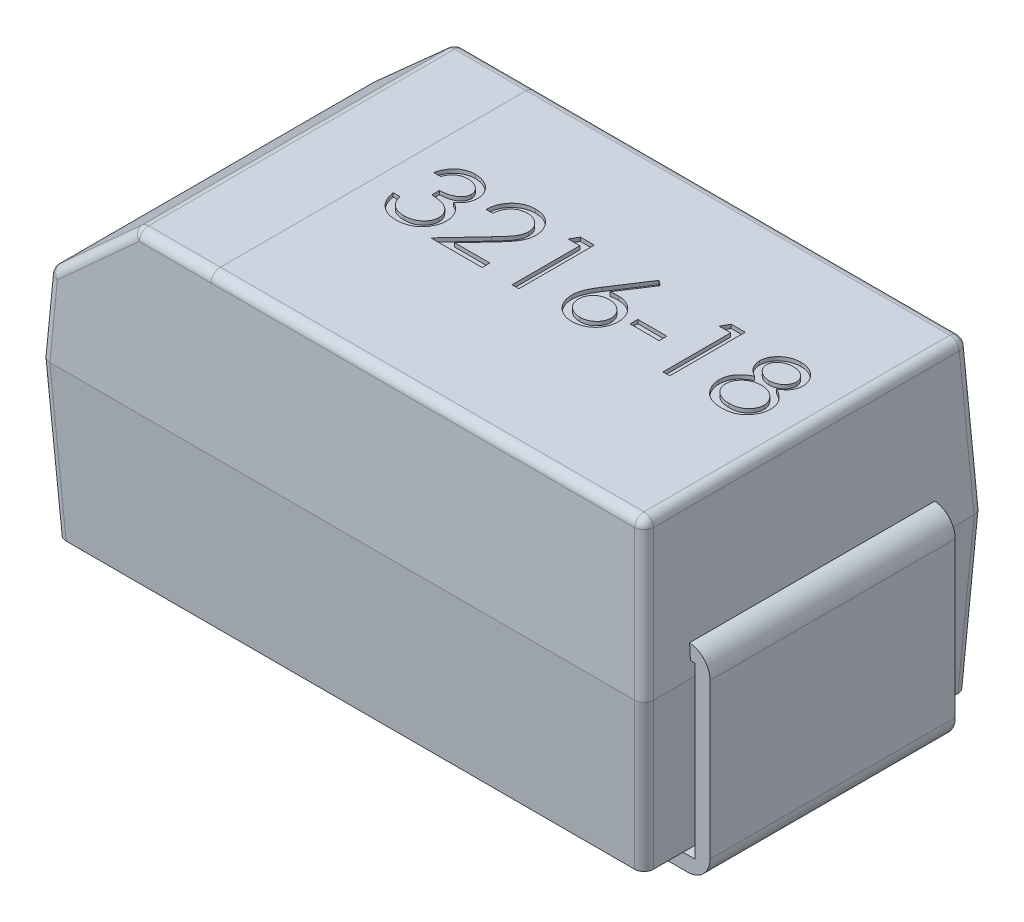
from build123d import *

# Parameters (mm, degrees)
SKETCH4_W                     = 3.2
SKETCH4_H                     = 1.8
BOSS_EXTRUDE2_DEPTH           = 0.82
BOSS_EXTRUDE2_TAPER           = 3
BOSS_EXTRUDE2_OTHER_WAY_DEPTH = 0.8
BOSS_EXTRUDE2_OTHER_WAY_TAPER = 3
SKETCH5_W                     = 1.1
SKETCH5_H                     = 1.3
BOSS_EXTRUDE3_DEPTH           = 0.06
BOSS_EXTRUDE7_DEPTH           = 0.65
BOSS_EXTRUDE7_2_DEPTH         = 0.65
CHAMFER1_SIZE                 = 0.4
CHAMFER1_SIZE2                = 0.422701801
SKETCH11_W                    = 0.153846154
SKETCH11_H                    = 0.041025641
CUT_EXTRUDE2_DEPTH            = 0.02
FILLET6_R                     = 0.05


with BuildPart() as part:
    # Sketch4 → Boss-Extrude2 (new body)
    with BuildSketch(Plane(origin=(0, 0.9, 0), x_dir=(-1, 0, 0), z_dir=(0, 1, 0))):
        Rectangle(SKETCH4_W, SKETCH4_H)
    extrude(amount=-BOSS_EXTRUDE2_DEPTH, taper=BOSS_EXTRUDE2_TAPER)

    # Sketch4 → Boss-Extrude2 other way (add)
    with BuildSketch(Plane(origin=(0, 0.9, 0), x_dir=(-1, 0, 0), z_dir=(0, 1, 0))):
        Rectangle(SKETCH4_W, SKETCH4_H)
    extrude(amount=BOSS_EXTRUDE2_OTHER_WAY_DEPTH, taper=BOSS_EXTRUDE2_OTHER_WAY_TAPER)

    # Sketch5 → Boss-Extrude3 (add)
    with BuildSketch(Plane.XZ.offset(-0.08)):
        Rectangle(SKETCH5_W, SKETCH5_H)
    extrude(amount=BOSS_EXTRUDE3_DEPTH)

    # Chamfer1
    chamfer1_edges = [part.edges().sort_by_distance(p)[0] for p in [
        (-1.558073777, 1.7, 0),
    ]]
    chamfer1_side = [part.faces().sort_by_distance(p)[0] for p in [
        (-1.57920353, 1.296820291, 0),
    ]]
    chamfer(chamfer1_edges, length=CHAMFER1_SIZE, length2=CHAMFER1_SIZE2, reference=chamfer1_side[0])

    # Sketch11 → Cut-Extrude2 (cut)
    with BuildSketch(Plane(origin=(0, 1.7, 0), x_dir=(1, 0, 0), z_dir=(0, 1, 0))):
        with BuildLine():
            Line((-0.568705309, 0.189618531), (-0.604602745, 0.189618531))
            add(Edge.make_bspline(
                [(-0.604602745, 0.189618531), (-0.603630225, 0.193645101), (-0.601729027, 0.201516715), (-0.59776359, 0.212763259), (-0.593443676, 0.223405947), (-0.588256349, 0.233245498), (-0.582598206, 0.242479659), (-0.576115609, 0.250898987), (-0.569107641, 0.258717612), (-0.561356218, 0.265656268), (-0.553227228, 0.271939437), (-0.544606129, 0.277296586), (-0.53566637, 0.281905061), (-0.526346012, 0.285701659), (-0.516617306, 0.288561718), (-0.506568206, 0.290636782), (-0.496172378, 0.291984338), (-0.48911551, 0.292115854), (-0.485532232, 0.292182634)],
                knots=[0, 0, 0, 0, 1.162005537, 2.271625781, 3.343758855, 4.383309926, 5.390229558, 6.379919256, 7.361854164, 8.333198761, 9.295911338, 10.242430842, 11.177959212, 12.116337295, 13.062827104, 14.020064771, 14.994644689, 16, 16, 16, 16], degree=3))
            add(Edge.make_bspline(
                [(-0.485532232, 0.292182634), (-0.480311347, 0.292025007), (-0.46998346, 0.291713193), (-0.45481054, 0.288865829), (-0.440178904, 0.284360099), (-0.426248704, 0.278134531), (-0.413309455, 0.270455981), (-0.401796748, 0.261317153), (-0.391866632, 0.250894376), (-0.383535846, 0.239382083), (-0.377012989, 0.227078596), (-0.372203118, 0.214415721), (-0.369274926, 0.201423496), (-0.368895434, 0.192651235), (-0.368705309, 0.188256352)],
                knots=[0, 0, 0, 0, 1.083050992, 2.142477498, 3.193116406, 4.255571735, 5.30263384, 6.308962982, 7.297363603, 8.282367274, 9.249857812, 10.179914175, 11.08814088, 12, 12, 12, 12], degree=3))
            add(Edge.make_bspline(
                [(-0.368705309, 0.188256352), (-0.368838291, 0.184027004), (-0.369098515, 0.175750826), (-0.371308082, 0.163668369), (-0.375026512, 0.152280758), (-0.380177342, 0.141540053), (-0.386844948, 0.131514358), (-0.394921827, 0.122181113), (-0.404464989, 0.113498923), (-0.411696867, 0.108525269), (-0.415420052, 0.105964685)],
                knots=[0, 0, 0, 0, 1.024540389, 2.004866551, 2.965041327, 3.920577974, 4.882998113, 5.874504559, 6.905732034, 8, 8, 8, 8], degree=3))
            add(Edge.make_bspline(
                [(-0.415420052, 0.105964685), (-0.411164995, 0.103910037), (-0.402734495, 0.099839184), (-0.391243006, 0.091855669), (-0.380811249, 0.082637801), (-0.374993681, 0.075444355), (-0.372070693, 0.07183007)],
                knots=[0, 0, 0, 0, 1.015518401, 2.012035669, 3.001164323, 4, 4, 4, 4], degree=3))
            add(Edge.make_bspline(
                [(-0.372070693, 0.07183007), (-0.370145969, 0.069194898), (-0.366328038, 0.063967708), (-0.361615405, 0.055563545), (-0.357340078, 0.047066231), (-0.354008624, 0.038248014), (-0.351428754, 0.029211098), (-0.349584636, 0.019939967), (-0.34843902, 0.01042705), (-0.348274957, 0.003991338), (-0.348192488, 0.000756352)],
                knots=[0, 0, 0, 0, 1.025084078, 2.033381695, 3.024893161, 4.013698104, 4.991890475, 5.976764909, 6.982997093, 8, 8, 8, 8], degree=3))
            add(Edge.make_bspline(
                [(-0.348192488, 0.000756352), (-0.348397576, -0.004844759), (-0.348806785, -0.016020622), (-0.352464393, -0.032532019), (-0.358134478, -0.048672077), (-0.366186699, -0.064109201), (-0.376000129, -0.078552673), (-0.387675252, -0.09147568), (-0.401079413, -0.102584092), (-0.41602863, -0.111865261), (-0.432224873, -0.119284452), (-0.449547798, -0.124433874), (-0.467747804, -0.127787702), (-0.480228638, -0.128147345), (-0.486573899, -0.128330187)],
                knots=[0, 0, 0, 0, 0.955779014, 1.907060117, 2.875433937, 3.871313158, 4.872415639, 5.851225146, 6.836215519, 7.83643374, 8.849228613, 9.86973379, 10.916971861, 12, 12, 12, 12], degree=3))
            add(Edge.make_bspline(
                [(-0.486573899, -0.128330187), (-0.49085039, -0.128230962), (-0.499265099, -0.128035722), (-0.511635785, -0.126701025), (-0.523443979, -0.12426331), (-0.534705647, -0.120982932), (-0.545430794, -0.116823876), (-0.555586692, -0.111644596), (-0.565235823, -0.105551853), (-0.574287131, -0.098473729), (-0.582739539, -0.090555861), (-0.590368422, -0.081657689), (-0.59730097, -0.0719437), (-0.603351557, -0.061301065), (-0.60879578, -0.049867321), (-0.613273604, -0.037496064), (-0.617214812, -0.02429789), (-0.619047207, -0.015100434), (-0.61998736, -0.010381469)],
                knots=[0, 0, 0, 0, 1.048658725, 2.063410685, 3.046034179, 4.001477787, 4.936774919, 5.862367409, 6.792675028, 7.730719943, 8.675894397, 9.627829632, 10.600096036, 11.597688215, 12.626045268, 13.701542398, 14.82072376, 16, 16, 16, 16], degree=3))
            Line((-0.61998736, -0.010381469), (-0.584089924, -0.010381469))
            add(Edge.make_bspline(
                [(-0.584089924, -0.010381469), (-0.583154691, -0.013461356), (-0.581335581, -0.019452004), (-0.57823909, -0.028073754), (-0.574711287, -0.035977531), (-0.570926766, -0.043221316), (-0.566952087, -0.049876448), (-0.562504667, -0.055766947), (-0.557913907, -0.061151542), (-0.55445341, -0.064185212), (-0.552759796, -0.06566993)],
                knots=[0, 0, 0, 0, 1.198163088, 2.33053128, 3.407730985, 4.417276592, 5.372219308, 6.28897303, 7.162600585, 8, 8, 8, 8], degree=3))
            add(Edge.make_bspline(
                [(-0.552759796, -0.06566993), (-0.550520187, -0.067396597), (-0.546047883, -0.070844601), (-0.538760085, -0.075244787), (-0.531095527, -0.079057476), (-0.522888135, -0.081969898), (-0.514315019, -0.084435916), (-0.505237606, -0.08604969), (-0.495735981, -0.087156909), (-0.489248236, -0.087254616), (-0.485932873, -0.087304546)],
                knots=[0, 0, 0, 0, 0.946170439, 1.889420265, 2.845303464, 3.807233317, 4.801018734, 5.828864929, 6.890507805, 8, 8, 8, 8], degree=3))
            add(Edge.make_bspline(
                [(-0.485932873, -0.087304546), (-0.482189615, -0.087234157), (-0.474869999, -0.087096517), (-0.464189443, -0.085830722), (-0.454028592, -0.083987246), (-0.444500258, -0.081140048), (-0.435479628, -0.077622236), (-0.427093154, -0.073205276), (-0.419230742, -0.068023022), (-0.411993096, -0.062132832), (-0.405485038, -0.055684661), (-0.399754808, -0.04894031), (-0.394883418, -0.041928215), (-0.390953866, -0.034609573), (-0.387850946, -0.02701469), (-0.38573858, -0.019122252), (-0.384269836, -0.01099685), (-0.384150223, -0.00547354), (-0.384089924, -0.002689161)],
                knots=[0, 0, 0, 0, 1.217147791, 2.380027433, 3.494444702, 4.572153297, 5.609568379, 6.639424714, 7.649109417, 8.668170816, 9.669597737, 10.625200337, 11.543417969, 12.441394052, 13.322311151, 14.205496177, 15.095365482, 16, 16, 16, 16], degree=3))
            add(Edge.make_bspline(
                [(-0.384089924, -0.002689161), (-0.384264816, 0.001037849), (-0.384613729, 0.008473324), (-0.387277566, 0.019412476), (-0.391659151, 0.029952294), (-0.397793152, 0.039912956), (-0.405260093, 0.049144487), (-0.413987511, 0.057381228), (-0.424047879, 0.06417781), (-0.433307293, 0.068873657), (-0.441509025, 0.072077894), (-0.448527926, 0.074212175), (-0.456385824, 0.07601945), (-0.464987692, 0.077700853), (-0.474398346, 0.079131864), (-0.484607539, 0.080325214), (-0.49561734, 0.081280076), (-0.503239187, 0.081706487), (-0.507166847, 0.081926223)],
                knots=[0, 0, 0, 0, 1.07054697, 2.135767047, 3.216561865, 4.33974944, 5.486079747, 6.621378074, 7.775625952, 8.963672916, 9.598146892, 10.304877434, 11.070270905, 11.915000392, 12.823868403, 13.805723172, 14.86925407, 16, 16, 16, 16], degree=3))
            Line((-0.507166847, 0.081926223), (-0.507166847, 0.122951864))
            add(Edge.make_bspline(
                [(-0.507166847, 0.122951864), (-0.502218143, 0.123035842), (-0.492524846, 0.123200333), (-0.478365497, 0.12518982), (-0.46482569, 0.127941892), (-0.452205491, 0.132157343), (-0.44070278, 0.137053377), (-0.430723397, 0.142750772), (-0.422407152, 0.149083886), (-0.415794458, 0.15615047), (-0.410819689, 0.163729333), (-0.407182341, 0.171628379), (-0.405033732, 0.179916843), (-0.404746913, 0.185573377), (-0.404602745, 0.188416608)],
                knots=[0, 0, 0, 0, 1.321986639, 2.589447074, 3.816329219, 5.01088745, 6.139805852, 7.153945165, 8.075214402, 8.924034688, 9.728124013, 10.488707548, 11.240355623, 12, 12, 12, 12], degree=3))
            add(Edge.make_bspline(
                [(-0.404602745, 0.188416608), (-0.404650106, 0.190505493), (-0.404744329, 0.194661231), (-0.405932589, 0.200732668), (-0.407718194, 0.20661849), (-0.41017302, 0.212293668), (-0.413458757, 0.217718842), (-0.41739087, 0.222940265), (-0.422072938, 0.227928126), (-0.427438132, 0.232577305), (-0.433199482, 0.237008075), (-0.439513742, 0.240769633), (-0.446190527, 0.243986212), (-0.453237231, 0.246638727), (-0.46067672, 0.248634074), (-0.468474041, 0.250066741), (-0.476644062, 0.250962473), (-0.482217974, 0.251091435), (-0.485051463, 0.251156993)],
                knots=[0, 0, 0, 0, 0.884392785, 1.759457502, 2.611959086, 3.489218968, 4.37281399, 5.2945488, 6.255912374, 7.266815255, 8.301784654, 9.332968512, 10.37626691, 11.440494194, 12.520033166, 13.637162961, 14.798855837, 16, 16, 16, 16], degree=3))
            add(Edge.make_bspline(
                [(-0.485051463, 0.251156993), (-0.489605939, 0.25099798), (-0.498501891, 0.250687391), (-0.511326453, 0.247967046), (-0.523248662, 0.243626694), (-0.532361653, 0.238445778), (-0.53909109, 0.233331442), (-0.543899883, 0.228864884), (-0.548622227, 0.223901133), (-0.552947447, 0.218134461), (-0.557321616, 0.211955399), (-0.561303851, 0.205049836), (-0.56517353, 0.197597905), (-0.56750525, 0.192329832), (-0.568705309, 0.189618531)],
                knots=[0, 0, 0, 0, 1.472543308, 2.876219568, 4.221790263, 5.565193594, 6.249813518, 6.953379497, 7.687249741, 8.463570142, 9.283606569, 10.136032583, 11.040678096, 12, 12, 12, 12], degree=3))
        make_face()
        with BuildLine():
            Line((-0.261013001, 0.1588493), (-0.296910437, 0.1588493))
            add(Edge.make_bspline(
                [(-0.296910437, 0.1588493), (-0.296676477, 0.163611688), (-0.296216985, 0.172964889), (-0.29406518, 0.186601907), (-0.290986223, 0.199636741), (-0.286632914, 0.211964731), (-0.281226482, 0.223694881), (-0.27474305, 0.234780597), (-0.267063753, 0.24517959), (-0.258354412, 0.254795458), (-0.248895139, 0.263616894), (-0.238688746, 0.271234636), (-0.2279636, 0.277670942), (-0.21675224, 0.283051655), (-0.204928176, 0.287090495), (-0.192598706, 0.290087253), (-0.179709662, 0.291890264), (-0.170927945, 0.292084068), (-0.166461719, 0.292182634)],
                knots=[0, 0, 0, 0, 1.10065271, 2.161652631, 3.183658789, 4.190468796, 5.17591951, 6.163126047, 7.15150782, 8.156236427, 9.156009102, 10.134482811, 11.092018607, 12.041330605, 13.001268258, 13.972401359, 14.968799086, 16, 16, 16, 16], degree=3))
            add(Edge.make_bspline(
                [(-0.166461719, 0.292182634), (-0.162075653, 0.292079953), (-0.153457191, 0.291878189), (-0.140878675, 0.2901455), (-0.128904127, 0.287431718), (-0.117556954, 0.283624242), (-0.106927689, 0.278506022), (-0.096936484, 0.272357731), (-0.087464392, 0.265246894), (-0.078937902, 0.256875029), (-0.071108407, 0.247937614), (-0.064353864, 0.238396139), (-0.058569502, 0.228541364), (-0.053748053, 0.218298141), (-0.05019878, 0.207570023), (-0.047504128, 0.1965132), (-0.045980995, 0.185013221), (-0.045747232, 0.177229615), (-0.045628386, 0.173272377)],
                knots=[0, 0, 0, 0, 1.111607364, 2.184268762, 3.212621178, 4.221274766, 5.211760367, 6.196651075, 7.1921475, 8.207485113, 9.220403448, 10.201281604, 11.166441695, 12.114753415, 13.065576456, 14.026450734, 14.996634279, 16, 16, 16, 16], degree=3))
            add(Edge.make_bspline(
                [(-0.045628386, 0.173272377), (-0.045821901, 0.167701196), (-0.046205537, 0.1566566), (-0.04948718, 0.14042633), (-0.054612496, 0.124701368), (-0.060783622, 0.112045676), (-0.067009044, 0.101847563), (-0.072619045, 0.093451139), (-0.079186452, 0.084410515), (-0.086806852, 0.074755962), (-0.095322609, 0.064411858), (-0.104810856, 0.053384453), (-0.115339254, 0.041787679), (-0.122728797, 0.033867039), (-0.126557873, 0.029762762)],
                knots=[0, 0, 0, 0, 1.184426356, 2.348067706, 3.509069118, 4.696110526, 5.333549288, 6.050745305, 6.844228056, 7.710549037, 8.667450064, 9.695053472, 10.805634456, 12, 12, 12, 12], degree=3))
            Line((-0.126557873, 0.029762762), (-0.226638001, -0.077048136))
            Line((-0.226638001, -0.077048136), (-0.040500181, -0.077048136))
            Line((-0.040500181, -0.077048136), (-0.040500181, -0.118073777))
            Line((-0.040500181, -0.118073777), (-0.312295052, -0.118073777))
            Line((-0.312295052, -0.118073777), (-0.157166847, 0.047471095))
            add(Edge.make_bspline(
                [(-0.157166847, 0.047471095), (-0.153389946, 0.051413759), (-0.146135291, 0.058986809), (-0.135874425, 0.070043147), (-0.126658541, 0.080300237), (-0.118427982, 0.0897387), (-0.111361296, 0.098496594), (-0.105090183, 0.106290274), (-0.100065544, 0.113462211), (-0.094612356, 0.121775424), (-0.089330758, 0.131925403), (-0.084792203, 0.144329253), (-0.082024792, 0.157098082), (-0.081692811, 0.165726887), (-0.081525822, 0.170067249)],
                knots=[0, 0, 0, 0, 1.329631726, 2.553950428, 3.673215718, 4.687767853, 5.603093632, 6.413772471, 7.123043292, 7.734684054, 8.834405432, 9.900288307, 10.943827018, 12, 12, 12, 12], degree=3))
            add(Edge.make_bspline(
                [(-0.081525822, 0.170067249), (-0.081598478, 0.172796552), (-0.081741669, 0.178175483), (-0.083005406, 0.186061856), (-0.084915178, 0.193669263), (-0.087651779, 0.201021105), (-0.091263978, 0.208043465), (-0.095660936, 0.214744892), (-0.100734086, 0.221223631), (-0.106602803, 0.227298293), (-0.113049833, 0.23286186), (-0.119860605, 0.237790326), (-0.127066331, 0.241909082), (-0.134636631, 0.245285482), (-0.142550399, 0.247934097), (-0.150822941, 0.249769363), (-0.1594314, 0.250921647), (-0.165309514, 0.251077552), (-0.168304668, 0.251156993)],
                knots=[0, 0, 0, 0, 0.991446411, 1.95395049, 2.89581595, 3.838931463, 4.798493298, 5.75982156, 6.748411868, 7.785213223, 8.824556874, 9.840280684, 10.836137867, 11.835679398, 12.848801643, 13.863922112, 14.911575587, 16, 16, 16, 16], degree=3))
            add(Edge.make_bspline(
                [(-0.168304668, 0.251156993), (-0.171432763, 0.251075275), (-0.177575825, 0.250914794), (-0.186595143, 0.249792204), (-0.195199232, 0.247855536), (-0.203409735, 0.245206774), (-0.211240545, 0.241840082), (-0.218653579, 0.23764674), (-0.225632195, 0.232642912), (-0.232189512, 0.226969706), (-0.238231109, 0.220653409), (-0.243539324, 0.21361227), (-0.248177497, 0.205974851), (-0.252224266, 0.19776176), (-0.255510631, 0.18889847), (-0.258021848, 0.179416447), (-0.260008916, 0.169356861), (-0.260672747, 0.162409994), (-0.261013001, 0.1588493)],
                knots=[0, 0, 0, 0, 1.031018746, 2.02475058, 2.990194455, 3.934040569, 4.864654155, 5.795059489, 6.735614925, 7.690564532, 8.649604399, 9.611025574, 10.590972636, 11.591080095, 12.624614302, 13.701020113, 14.821632451, 16, 16, 16, 16], degree=3))
        make_face()
        Polygon((0.080413281, 0.281926223), (0.154371614, 0.281926223), (0.154371614, -0.118073777), (0.118474178, -0.118073777), (0.118474178, 0.240900582), (0.056935717, 0.240900582), align=None)
        with BuildLine():
            Line((0.487704948, 0.292182634), (0.515349178, 0.27046789))
            Line((0.515349178, 0.27046789), (0.409660076, 0.1088493))
            add(Edge.make_bspline(
                [(0.409660076, 0.1088493), (0.416696679, 0.109970884), (0.430422369, 0.112158661), (0.444315614, 0.112519569), (0.451086358, 0.112695454)],
                knots=[0, 0, 0, 0, 1.025318673, 2, 2, 2, 2], degree=3))
            add(Edge.make_bspline(
                [(0.451086358, 0.112695454), (0.455151786, 0.112586184), (0.46315446, 0.11237109), (0.474903809, 0.110715793), (0.486193973, 0.108107208), (0.496978158, 0.104304665), (0.50729507, 0.099447253), (0.517203915, 0.093625668), (0.52651843, 0.086539304), (0.535358565, 0.078623309), (0.543384519, 0.069855654), (0.550490354, 0.060552644), (0.55645913, 0.050723972), (0.561301864, 0.040374616), (0.565062422, 0.029520529), (0.567803867, 0.018175599), (0.569424392, 0.006332002), (0.569644448, -0.001722647), (0.56975623, -0.005814161)],
                knots=[0, 0, 0, 0, 1.04369286, 2.054478336, 3.041073146, 4.015093852, 4.984733326, 5.965804835, 6.960378782, 7.985147595, 9.009457201, 10.008161701, 10.986880575, 11.956520048, 12.937015923, 13.931873656, 14.949455224, 16, 16, 16, 16], degree=3))
            add(Edge.make_bspline(
                [(0.56975623, -0.005814161), (0.569593589, -0.011411842), (0.569273551, -0.022426752), (0.566084546, -0.038469804), (0.561129158, -0.05375352), (0.554046012, -0.068033883), (0.545248025, -0.081291319), (0.534519157, -0.09303823), (0.522239901, -0.103514805), (0.508355696, -0.112275562), (0.493413643, -0.119430196), (0.477716272, -0.124569081), (0.461416026, -0.127732906), (0.450352643, -0.128129546), (0.44475623, -0.128330187)],
                knots=[0, 0, 0, 0, 1.031375318, 2.029502543, 3.004789286, 3.987476834, 4.960371455, 5.9300674, 6.912260825, 7.929083631, 8.949397511, 9.960523116, 10.96833055, 12, 12, 12, 12], degree=3))
            add(Edge.make_bspline(
                [(0.44475623, -0.128330187), (0.43937375, -0.128155535), (0.428711999, -0.12780958), (0.413028251, -0.124727758), (0.397958192, -0.119732661), (0.383607406, -0.112851029), (0.370313621, -0.104158699), (0.358420406, -0.093694439), (0.34798706, -0.081681929), (0.339304246, -0.068123032), (0.332417534, -0.053552751), (0.327252971, -0.038359933), (0.324236258, -0.022599935), (0.323814708, -0.011916376), (0.323602383, -0.006535315)],
                knots=[0, 0, 0, 0, 1.012016664, 2.004627821, 2.994792927, 3.992885782, 4.990978636, 5.973936114, 6.964471063, 7.975201453, 8.993600317, 9.990122807, 10.98767138, 12, 12, 12, 12], degree=3))
            add(Edge.make_bspline(
                [(0.323602383, -0.006535315), (0.323737406, -0.002415934), (0.324013095, 0.005995055), (0.325938054, 0.018733801), (0.329031174, 0.03176821), (0.332495202, 0.042825832), (0.336155272, 0.051884292), (0.339201276, 0.059187548), (0.34299259, 0.066703099), (0.347035262, 0.074688658), (0.35169319, 0.082938421), (0.356757836, 0.091590269), (0.362369224, 0.100506604), (0.366302957, 0.106557369), (0.368313922, 0.109650582)],
                knots=[0, 0, 0, 0, 1.173818275, 2.396712641, 3.66331629, 4.989737886, 5.693666774, 6.447286557, 7.243889047, 8.091586357, 8.998013824, 9.943181721, 10.948533338, 12, 12, 12, 12], degree=3))
            Line((0.368313922, 0.109650582), (0.487704948, 0.292182634))
        make_face()
        with BuildLine():
            add(Edge.make_bspline(
                [(0.443554307, 0.071669813), (0.440507193, 0.071580894), (0.434555295, 0.071407209), (0.425823019, 0.070398608), (0.417558647, 0.068499287), (0.409652689, 0.066080277), (0.402252951, 0.062754213), (0.395305656, 0.058714008), (0.388783935, 0.053957302), (0.382756101, 0.048551483), (0.377290996, 0.042632851), (0.372584581, 0.036293477), (0.368524879, 0.029686139), (0.365224099, 0.022755632), (0.362653805, 0.015504603), (0.360794576, 0.007966403), (0.359759862, 9.0483e-05), (0.359587721, -0.005250375), (0.359499819, -0.007977623)],
                knots=[0, 0, 0, 0, 1.129588631, 2.206414736, 3.251139165, 4.268635594, 5.265702196, 6.250456724, 7.242448911, 8.251968645, 9.246821453, 10.222880186, 11.173611482, 12.116736599, 13.062300278, 14.020270554, 14.989073742, 16, 16, 16, 16], degree=3))
            add(Edge.make_bspline(
                [(0.359499819, -0.007977623), (0.359571404, -0.010680478), (0.359711769, -0.015980374), (0.36098632, -0.023790565), (0.362933187, -0.031306555), (0.365829232, -0.038489595), (0.369283734, -0.045449174), (0.373844342, -0.051933207), (0.378897689, -0.0583355), (0.384938139, -0.06416424), (0.391420809, -0.069587854), (0.39834666, -0.074328455), (0.405564941, -0.078384017), (0.413173104, -0.081562428), (0.421063205, -0.084170918), (0.429300983, -0.086006516), (0.437892166, -0.08704429), (0.443711816, -0.087216655), (0.446679307, -0.087304546)],
                knots=[0, 0, 0, 0, 0.989467248, 1.94019797, 2.891935182, 3.827694429, 4.772920941, 5.730924762, 6.725747692, 7.756678648, 8.79901574, 9.819492441, 10.826891316, 11.826466727, 12.835195252, 13.867842842, 14.912794438, 16, 16, 16, 16], degree=3))
            add(Edge.make_bspline(
                [(0.446679307, -0.087304546), (0.449646792, -0.087216649), (0.455466433, -0.08704427), (0.464057685, -0.086006594), (0.472295207, -0.084170634), (0.480186237, -0.08156346), (0.487790972, -0.07838019), (0.49500294, -0.074353685), (0.501863294, -0.0695587), (0.508350219, -0.064173509), (0.514365527, -0.058302326), (0.519540073, -0.051990357), (0.523961014, -0.045396769), (0.527553492, -0.03851701), (0.53041764, -0.031302212), (0.532374379, -0.023791729), (0.533646298, -0.015980069), (0.533787025, -0.010680375), (0.533858794, -0.007977623)],
                knots=[0, 0, 0, 0, 1.087397944, 2.132534446, 3.165364764, 4.174271784, 5.174024072, 6.181601208, 7.194203697, 8.236725232, 9.267838612, 10.269026844, 11.221737037, 12.171628256, 13.107553087, 14.05945871, 15.010357665, 16, 16, 16, 16], degree=3))
            add(Edge.make_bspline(
                [(0.533858794, -0.007977623), (0.533795903, -0.005246817), (0.533672469, 0.000112867), (0.532276361, 0.00796288), (0.53034009, 0.015542904), (0.527416315, 0.022805298), (0.523617852, 0.029721404), (0.518991177, 0.036326158), (0.513638884, 0.042670198), (0.507456308, 0.048563091), (0.500725995, 0.053951328), (0.493569928, 0.058707849), (0.486083303, 0.062722132), (0.478273709, 0.066071515), (0.470051666, 0.068488598), (0.461549912, 0.070391825), (0.452659713, 0.071404627), (0.446628101, 0.071580292), (0.443554307, 0.071669813)],
                knots=[0, 0, 0, 0, 0.978206639, 1.919901502, 2.851605144, 3.780102724, 4.718870031, 5.675451981, 6.667674623, 7.690630536, 8.733308323, 9.756129687, 10.767539656, 11.776269907, 12.797430371, 13.836405707, 14.897401972, 16, 16, 16, 16], degree=3))
        make_face(mode=Mode.SUBTRACT)
        with Locations((0.687704948, 0.035772378)):
            Rectangle(SKETCH11_W, SKETCH11_H)
        Polygon((0.880413281, 0.281926223), (0.954371614, 0.281926223), (0.954371614, -0.118073777), (0.918474178, -0.118073777), (0.918474178, 0.240900582), (0.856935717, 0.240900582), align=None)
        with BuildLine():
            add(Edge.make_bspline(
                [(1.297560717, 0.104762762), (1.300834837, 0.103055567), (1.307220463, 0.099725967), (1.316315001, 0.094364729), (1.32462643, 0.088714333), (1.332385351, 0.083041664), (1.339455449, 0.077129475), (1.345757667, 0.070954257), (1.351447681, 0.064670149), (1.356410742, 0.058170739), (1.360776095, 0.051473293), (1.36454891, 0.044560233), (1.367773733, 0.037446709), (1.370329498, 0.030055072), (1.372434845, 0.022493899), (1.373883486, 0.014665558), (1.374662562, 0.006621633), (1.374809855, 0.001185256), (1.374884435, -0.001567366)],
                knots=[0, 0, 0, 0, 1.272397273, 2.481599622, 3.635517121, 4.734568067, 5.792894095, 6.808321871, 7.773003508, 8.711915296, 9.623354172, 10.525449501, 11.423591555, 12.311487226, 13.218079475, 14.126165749, 15.051214107, 16, 16, 16, 16], degree=3))
            add(Edge.make_bspline(
                [(1.374884435, -0.001567366), (1.374796272, -0.005418536), (1.374621766, -0.013041445), (1.373101768, -0.024292429), (1.370825999, -0.03521949), (1.367502626, -0.045820232), (1.363192524, -0.05603616), (1.357880886, -0.06587602), (1.351868177, -0.075501084), (1.347039349, -0.081423301), (1.344595973, -0.08441993)],
                knots=[0, 0, 0, 0, 1.025265484, 2.029385089, 3.018602448, 3.995076438, 4.983346944, 5.966715145, 6.97116228, 8, 8, 8, 8], degree=3))
            add(Edge.make_bspline(
                [(1.344595973, -0.08441993), (1.341414662, -0.087916362), (1.335091352, -0.094866018), (1.324259017, -0.103888968), (1.312370802, -0.111471756), (1.299472707, -0.117651401), (1.285599209, -0.122461213), (1.270753266, -0.125917501), (1.254905934, -0.127897207), (1.24401388, -0.128183377), (1.238426101, -0.128330187)],
                knots=[0, 0, 0, 0, 0.954267603, 1.896743057, 2.838368354, 3.796610408, 4.779680527, 5.799409237, 6.871065594, 8, 8, 8, 8], degree=3))
            add(Edge.make_bspline(
                [(1.238426101, -0.128330187), (1.233053143, -0.128198475), (1.222597911, -0.127942177), (1.207379868, -0.126205671), (1.193194374, -0.123162486), (1.179958949, -0.118997388), (1.167753384, -0.113579076), (1.156612458, -0.106835258), (1.146375433, -0.099037379), (1.137352979, -0.089961484), (1.129342871, -0.080240585), (1.122306522, -0.070211829), (1.116458056, -0.059874303), (1.111506388, -0.049382146), (1.107715757, -0.0385883), (1.105090361, -0.027548299), (1.103423011, -0.016281425), (1.103201167, -0.008677808), (1.103089563, -0.004852623)],
                knots=[0, 0, 0, 0, 1.256902934, 2.445805442, 3.576955095, 4.645999104, 5.686449165, 6.692658513, 7.68621702, 8.689161843, 9.678783111, 10.630372946, 11.551080876, 12.453998257, 13.34127905, 14.221779781, 15.105423033, 16, 16, 16, 16], degree=3))
            add(Edge.make_bspline(
                [(1.103089563, -0.004852623), (1.103155607, -0.002045858), (1.103286132, 0.0035013), (1.104189543, 0.011696652), (1.105641939, 0.019673353), (1.107614448, 0.027460866), (1.110287708, 0.035002498), (1.113515381, 0.04233398), (1.117279032, 0.049463592), (1.121631165, 0.056430321), (1.126694254, 0.063136551), (1.132427242, 0.069696093), (1.138944713, 0.076007164), (1.14617416, 0.082146869), (1.154032964, 0.088224124), (1.162725254, 0.093910492), (1.172020598, 0.099608546), (1.178626931, 0.103015211), (1.182015845, 0.104762762)],
                knots=[0, 0, 0, 0, 0.941657376, 1.861047343, 2.762797495, 3.66048619, 4.553285746, 5.444104102, 6.34607688, 7.256116206, 8.197091036, 9.162375105, 10.176350973, 11.237807142, 12.343728897, 13.50695164, 14.721116704, 16, 16, 16, 16], degree=3))
            add(Edge.make_bspline(
                [(1.182015845, 0.104762762), (1.177376831, 0.10729245), (1.168394401, 0.112190633), (1.15650075, 0.121190268), (1.146284679, 0.130937447), (1.138026997, 0.141637995), (1.131527314, 0.152957638), (1.127068045, 0.164825553), (1.124051304, 0.17702168), (1.123752466, 0.185353817), (1.123602383, 0.189538403)],
                knots=[0, 0, 0, 0, 1.166880483, 2.259407225, 3.286803203, 4.280235371, 5.237608625, 6.161067461, 7.076446754, 8, 8, 8, 8], degree=3))
            add(Edge.make_bspline(
                [(1.123602383, 0.189538403), (1.123789289, 0.193800981), (1.124165002, 0.202369506), (1.127203096, 0.215124492), (1.132153961, 0.227652099), (1.138887789, 0.239891609), (1.147274899, 0.251428777), (1.157337362, 0.261776313), (1.168834881, 0.270840483), (1.181710066, 0.278449188), (1.195565636, 0.284641607), (1.210184576, 0.288913426), (1.225312175, 0.291706125), (1.235609057, 0.292022314), (1.240829948, 0.292182634)],
                knots=[0, 0, 0, 0, 0.888701115, 1.786444228, 2.72001202, 3.692817113, 4.693886446, 5.687152267, 6.695133018, 7.739871481, 8.800368666, 9.853104506, 10.91144658, 12, 12, 12, 12], degree=3))
            add(Edge.make_bspline(
                [(1.240829948, 0.292182634), (1.245916098, 0.292017337), (1.255945407, 0.291691392), (1.27068765, 0.288972891), (1.28479335, 0.284432375), (1.298213864, 0.278272692), (1.310708935, 0.270685613), (1.321749199, 0.261496942), (1.331501494, 0.25119505), (1.339568282, 0.239661381), (1.346215469, 0.227468902), (1.350844144, 0.214712043), (1.353810084, 0.201666436), (1.354184182, 0.192839235), (1.354371614, 0.188416608)],
                knots=[0, 0, 0, 0, 1.072916533, 2.115669174, 3.151510826, 4.193348718, 5.225979165, 6.227137561, 7.216255879, 8.211077061, 9.189680878, 10.138522389, 11.067357538, 12, 12, 12, 12], degree=3))
            add(Edge.make_bspline(
                [(1.354371614, 0.188416608), (1.354207664, 0.184076418), (1.353885676, 0.175552531), (1.351177112, 0.163126643), (1.34661559, 0.151489839), (1.340387686, 0.140510073), (1.332270487, 0.130386473), (1.322372347, 0.120990305), (1.310772178, 0.112244382), (1.302056648, 0.107308797), (1.297560717, 0.104762762)],
                knots=[0, 0, 0, 0, 0.975232327, 1.915300861, 2.843280834, 3.77672583, 4.742871857, 5.749627742, 6.839139064, 8, 8, 8, 8], degree=3))
        make_face()
        with BuildLine():
            add(Edge.make_bspline(
                [(1.238826742, 0.251156993), (1.236020936, 0.251082542), (1.230531552, 0.250936885), (1.222482561, 0.250175898), (1.214828576, 0.24869553), (1.207489627, 0.246725392), (1.200566335, 0.244063907), (1.193964671, 0.240933049), (1.187796992, 0.237126642), (1.181988844, 0.23285679), (1.176760184, 0.228160458), (1.172119663, 0.223267462), (1.168265022, 0.218081703), (1.164991752, 0.212732176), (1.162616722, 0.20706011), (1.160837944, 0.201239404), (1.159635499, 0.195196503), (1.159545398, 0.191066616), (1.159499819, 0.188977505)],
                knots=[0, 0, 0, 0, 1.203892937, 2.355340988, 3.463153438, 4.544400666, 5.610487187, 6.640501085, 7.674077295, 8.714426146, 9.728707835, 10.68524104, 11.601827946, 12.495867327, 13.368432065, 14.231010473, 15.105153427, 16, 16, 16, 16], degree=3))
            add(Edge.make_bspline(
                [(1.159499819, 0.188977505), (1.159578376, 0.186888304), (1.159733614, 0.182759743), (1.1609342, 0.176663073), (1.162723555, 0.170672028), (1.165540773, 0.164929067), (1.168919786, 0.159234969), (1.17309024, 0.153732045), (1.178060415, 0.148401144), (1.183663551, 0.143287607), (1.189767727, 0.138499177), (1.196234474, 0.134342242), (1.202982633, 0.130864058), (1.20994287, 0.127969269), (1.217186121, 0.125718991), (1.224668004, 0.124122574), (1.232389775, 0.123130346), (1.237621842, 0.123011829), (1.24026905, 0.122951864)],
                knots=[0, 0, 0, 0, 0.873023192, 1.725219244, 2.590779336, 3.480155217, 4.391973325, 5.357036234, 6.360879153, 7.436073238, 8.526419356, 9.601555421, 10.645666583, 11.697338044, 12.750135903, 13.812665442, 14.89329948, 16, 16, 16, 16], degree=3))
            add(Edge.make_bspline(
                [(1.24026905, 0.122951864), (1.243669062, 0.123051621), (1.250435504, 0.123250148), (1.260410285, 0.125095996), (1.270108873, 0.12799953), (1.279427605, 0.131972097), (1.288125272, 0.136958138), (1.295878422, 0.142927626), (1.302620924, 0.149742723), (1.308282708, 0.157297333), (1.312672405, 0.165337514), (1.316089754, 0.173406119), (1.318085322, 0.181589231), (1.318345615, 0.18707117), (1.318474178, 0.189778788)],
                knots=[0, 0, 0, 0, 1.076279235, 2.141928126, 3.20205304, 4.278698113, 5.344010996, 6.36967002, 7.368914609, 8.37248503, 9.349703398, 10.264243087, 11.142681841, 12, 12, 12, 12], degree=3))
            add(Edge.make_bspline(
                [(1.318474178, 0.189778788), (1.31841339, 0.191679134), (1.318292734, 0.195451051), (1.317298442, 0.20102115), (1.31565549, 0.206464531), (1.313431138, 0.211826162), (1.310504304, 0.217030817), (1.307034111, 0.222160313), (1.302818739, 0.227099257), (1.298087718, 0.231962748), (1.292722529, 0.236463779), (1.28673351, 0.240422032), (1.280151367, 0.243783444), (1.272975945, 0.246513588), (1.265233668, 0.248564142), (1.256960196, 0.250099724), (1.248086545, 0.250965223), (1.241980288, 0.251091683), (1.238826742, 0.251156993)],
                knots=[0, 0, 0, 0, 0.814439003, 1.616544685, 2.417341072, 3.248991801, 4.09997495, 4.973547432, 5.9003056, 6.880240646, 7.880314356, 8.896779544, 9.951930927, 11.043077905, 12.18215768, 13.381699519, 14.647792085, 16, 16, 16, 16], degree=3))
        make_face(mode=Mode.SUBTRACT)
        with BuildLine():
            add(Edge.make_bspline(
                [(1.24115046, 0.081926223), (1.237593228, 0.08186295), (1.230614805, 0.081738823), (1.220391156, 0.080357166), (1.210579366, 0.078433807), (1.201212516, 0.075515997), (1.192294562, 0.071722112), (1.183777227, 0.067158165), (1.175725669, 0.061763257), (1.168251072, 0.05560593), (1.161425549, 0.048970563), (1.155437172, 0.041946319), (1.150351741, 0.034663744), (1.146256512, 0.027030347), (1.142895171, 0.019207762), (1.140687871, 0.01100118), (1.139272818, 0.002568367), (1.139082803, -0.003164215), (1.138986999, -0.006054546)],
                knots=[0, 0, 0, 0, 1.140299081, 2.23698856, 3.303958914, 4.344563908, 5.37730929, 6.408454204, 7.439741482, 8.480804886, 9.510774543, 10.48932336, 11.43758569, 12.353841022, 13.263987381, 14.161954604, 15.073269652, 16, 16, 16, 16], degree=3))
            add(Edge.make_bspline(
                [(1.138986999, -0.006054546), (1.1391428, -0.009646649), (1.139451905, -0.016773299), (1.141904093, -0.027306221), (1.145839582, -0.037502913), (1.151328179, -0.047280279), (1.158124473, -0.056417434), (1.166481783, -0.064381866), (1.175880736, -0.071458606), (1.186639348, -0.077182096), (1.198391173, -0.081752936), (1.211133085, -0.084902189), (1.224682218, -0.086986926), (1.2340376, -0.087197004), (1.238826742, -0.087304546)],
                knots=[0, 0, 0, 0, 0.898778495, 1.783155532, 2.693654817, 3.627872908, 4.583023416, 5.533784346, 6.509005473, 7.520592997, 8.575161974, 9.658835044, 10.801527049, 12, 12, 12, 12], degree=3))
            add(Edge.make_bspline(
                [(1.238826742, -0.087304546), (1.242569642, -0.087232682), (1.24986201, -0.087092668), (1.260500404, -0.085856749), (1.270539781, -0.083896792), (1.279960672, -0.081046101), (1.288868539, -0.077566103), (1.297112351, -0.073089294), (1.304904183, -0.0679976), (1.311860083, -0.061956668), (1.318195306, -0.055501869), (1.323719111, -0.048668721), (1.32851426, -0.041642934), (1.332277798, -0.034265736), (1.335286513, -0.02667866), (1.337449205, -0.018811744), (1.338783629, -0.010640861), (1.338918589, -0.00509811), (1.338986999, -0.00228852)],
                knots=[0, 0, 0, 0, 1.224942928, 2.386581632, 3.501229538, 4.569074225, 5.605009692, 6.626002462, 7.634866581, 8.645888296, 9.63523824, 10.59253846, 11.518950513, 12.414518923, 13.29783783, 14.186679152, 15.080837789, 16, 16, 16, 16], degree=3))
            add(Edge.make_bspline(
                [(1.338986999, -0.00228852), (1.338883473, 0.000440319), (1.338679339, 0.005821112), (1.337383717, 0.01379443), (1.335107617, 0.021497609), (1.331984486, 0.029023324), (1.327826662, 0.036219089), (1.322930105, 0.043272366), (1.317022206, 0.049987388), (1.31034648, 0.056416314), (1.303071171, 0.062360969), (1.295337783, 0.067619762), (1.287205844, 0.072048575), (1.278692563, 0.075650461), (1.269816842, 0.078483314), (1.26058521, 0.080462285), (1.250986859, 0.081707954), (1.244466302, 0.081852645), (1.24115046, 0.081926223)],
                knots=[0, 0, 0, 0, 0.917430815, 1.809013306, 2.70690318, 3.612392954, 4.541220862, 5.495268465, 6.494511384, 7.542276156, 8.608045339, 9.649016899, 10.681629292, 11.715607085, 12.752076957, 13.808767841, 14.885711793, 16, 16, 16, 16], degree=3))
        make_face(mode=Mode.SUBTRACT)
    extrude(amount=-CUT_EXTRUDE2_DEPTH, mode=Mode.SUBTRACT)

    # Fillet6
    fillet6_edges = [part.edges().sort_by_distance(p)[0] for p in [
        (1.57851281, 0.49, -0.87851281),
        (1.57851281, 0.49, 0.87851281),
        (-1.57851281, 0.49, 0.87851281),
        (-1.57851281, 0.49, -0.87851281),
        (0.211350901, 1.7, 0.858073777),
        (-1.135371975, 1.7, 0),
        (1.558073777, 1.7, 0),
        (-1.58950408, 1.100274093, 0.88950408),
        (-1.357190067, 1.500274093, 0.868540968),
        (-1.58950408, 1.100274093, -0.88950408),
        (-1.579008159, 1.300548186, 0),
        (-1.357190067, 1.500274093, -0.868540968),
        (0.211350901, 1.7, -0.858073777),
        (0.211350901, 1.7, 0.858073777),
        (0.211350901, 1.7, -0.858073777),
        (1.579036888, 1.3, 0.879036888),
        (1.579036888, 1.3, -0.879036888),
    ]]
    fillet(fillet6_edges, radius=FILLET6_R)


with BuildPart() as body_2:
    # Sketch14 → Boss-Extrude7 (new, symmetric)
    with BuildSketch(Plane.XY):
        with BuildLine():
            Line((-0.9, 1.06), (-0.9, 0.98))
            Line((-0.9, 0.98), (-1.62, 0.98))
            Line((-1.62, 0.98), (-1.62, 0.08))
            Line((-1.62, 0.08), (-0.9, 0.08))
            Line((-0.9, 0.08), (-0.9, 0))
            Line((-0.9, 0), (-1.58, 0))
            ThreePointArc((-1.58, 0), (-1.664852814, 0.035147186), (-1.7, 0.12))
            Line((-1.7, 0.12), (-1.7, 0.94))
            ThreePointArc((-1.7, 0.94), (-1.664852814, 1.024852814), (-1.58, 1.06))
            Line((-1.58, 1.06), (-0.9, 1.06))
        make_face()
    extrude(amount=BOSS_EXTRUDE7_DEPTH, both=True)


with BuildPart() as body_3:
    # Sketch14 → Boss-Extrude7 2 (new, symmetric)
    with BuildSketch(Plane.XY):
        with BuildLine():
            Line((1.58, 1.06), (0.9, 1.06))
            Line((0.9, 1.06), (0.9, 0.98))
            Line((0.9, 0.98), (1.62, 0.98))
            Line((1.62, 0.98), (1.62, 0.08))
            Line((1.62, 0.08), (0.9, 0.08))
            Line((0.9, 0.08), (0.9, 0))
            Line((0.9, 0), (1.58, 0))
            ThreePointArc((1.58, 0), (1.664852814, 0.035147186), (1.7, 0.12))
            Line((1.7, 0.12), (1.7, 0.94))
            ThreePointArc((1.7, 0.94), (1.664852814, 1.024852814), (1.58, 1.06))
        make_face()
    extrude(amount=BOSS_EXTRUDE7_2_DEPTH, both=True)


solid = Compound([part.part, body_2.part, body_3.part])
